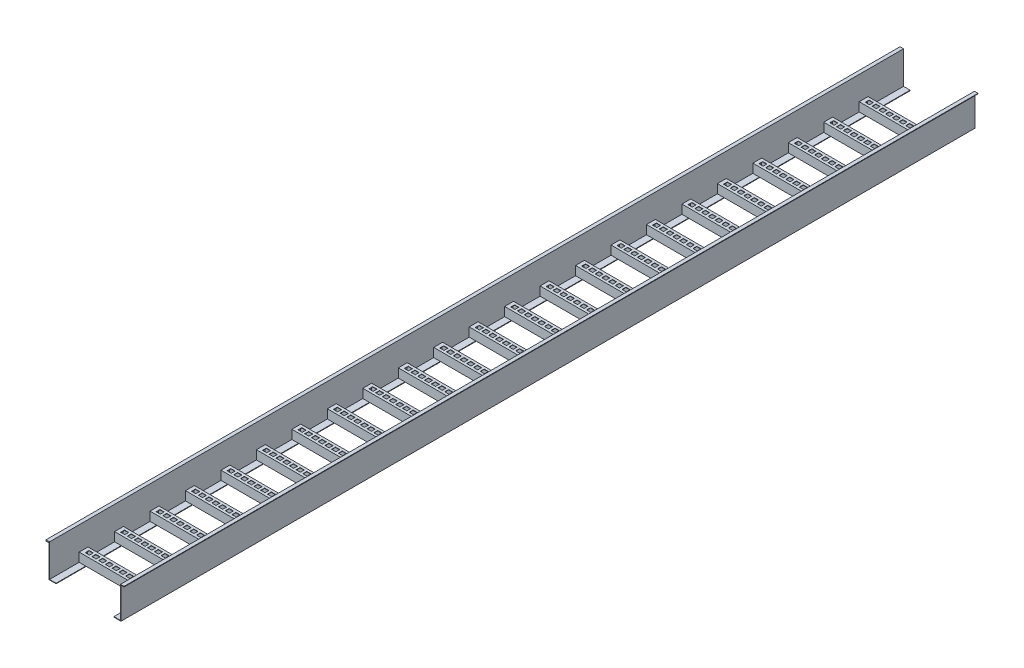
from build123d import *

# Parameters (mm, degrees)
SALIENTE_EXTRUIR1_DEPTH   = 2408.5
SALIENTE_EXTRUIR1_2_DEPTH = 2408.5
SALIENTE_EXTRUIR2_DEPTH   = 201.5
MATRIZL1_COUNT            = 23
MATRIZL1_PITCH            = 100
CROQUIS3_W                = 12
CROQUIS3_H                = 11
CORTAR_EXTRUIR1_DEPTH     = 25
MATRIZL2_COUNT            = 50
MATRIZL2_PITCH            = 100


with BuildPart() as part:
    # Croquis1 → Saliente-Extruir1 (new body)
    with BuildSketch(Plane.XY):
        Polygon((154.347826087, -11.915528294), (135.847826087, -11.915528294), (135.847826087, -13.415528294), (155.847826087, -13.415528294), (155.847826087, 74.627949967), (164.347826087, 74.627949967), (164.347826087, 76.127949967), (154.347826087, 76.127949967), align=None)
    extrude(amount=SALIENTE_EXTRUIR1_DEPTH)



with BuildPart() as body_2:
    # Croquis1 → Saliente-Extruir1 2 (new body)
    with BuildSketch(Plane.XY):
        Polygon((-45.652173913, 79.891304348), (-55.652173913, 79.891304348), (-55.652173913, 76.515391865), (-47.152173913, 76.515391865), (-47.152173913, -13.415528294), (-27.152173913, -13.415528294), (-27.152173913, -11.915528294), (-45.652173913, -11.915528294), align=None)
    extrude(amount=SALIENTE_EXTRUIR1_2_DEPTH)


with BuildPart() as part_1:
    add(part.part)

    add(body_2.part)  # Saliente-Extruir2 merges body 2
    # Croquis2 → Saliente-Extruir2 (add)
    with BuildSketch(Plane(origin=(155.847826087, 0, 0), x_dir=(0, 0, -1), z_dir=(1, 0, 0))):
        Polygon((-125, -11.915528294), (-124, -11.915528294), (-124, 12.084471706), (-101, 12.084471706), (-101, -11.915528294), (-100, -11.915528294), (-100, 13.084471706), (-125, 13.084471706), align=None)
    saliente_extruir2 = extrude(amount=-SALIENTE_EXTRUIR2_DEPTH)

    # MatrizL1: Saliente-Extruir2 ×23
    with Locations(*[(0, 0, i * MATRIZL1_PITCH) for i in range(1, MATRIZL1_COUNT)]):
        add(saliente_extruir2)

    # Croquis3 → Cortar-Extruir1 (cut)
    with BuildSketch(Plane(origin=(0, 13.084471706, 0), x_dir=(1, 0, 0), z_dir=(0, 1, 0))):
        with Locations((141.347826087, -112.5)):
            Rectangle(CROQUIS3_W, CROQUIS3_H)
        with Locations((122.347826087, -112.5)):
            Rectangle(CROQUIS3_W, CROQUIS3_H)
        with Locations((103.347826087, -112.5)):
            Rectangle(CROQUIS3_W, CROQUIS3_H)
        with Locations((84.347826087, -112.5)):
            Rectangle(CROQUIS3_W, CROQUIS3_H)
        with Locations((65.347826087, -112.5)):
            Rectangle(CROQUIS3_W, CROQUIS3_H)
        with Locations((46.347826087, -112.5)):
            Rectangle(CROQUIS3_W, CROQUIS3_H)
        with Locations((27.347826087, -112.5)):
            Rectangle(CROQUIS3_W, CROQUIS3_H)
        with Locations((8.347826087, -112.5)):
            Rectangle(CROQUIS3_W, CROQUIS3_H)
        with Locations((-10.652173913, -112.5)):
            Rectangle(CROQUIS3_W, CROQUIS3_H)
        with Locations((-29.652173913, -112.5)):
            Rectangle(CROQUIS3_W, CROQUIS3_H)
    cortar_extruir1 = extrude(amount=-CORTAR_EXTRUIR1_DEPTH, mode=Mode.SUBTRACT)

    # MatrizL2: Cortar-Extruir1 ×50
    with Locations(*[(0, 0, i * MATRIZL2_PITCH) for i in range(1, MATRIZL2_COUNT)]):
        add(cortar_extruir1, mode=Mode.SUBTRACT)


solid = part_1.part
